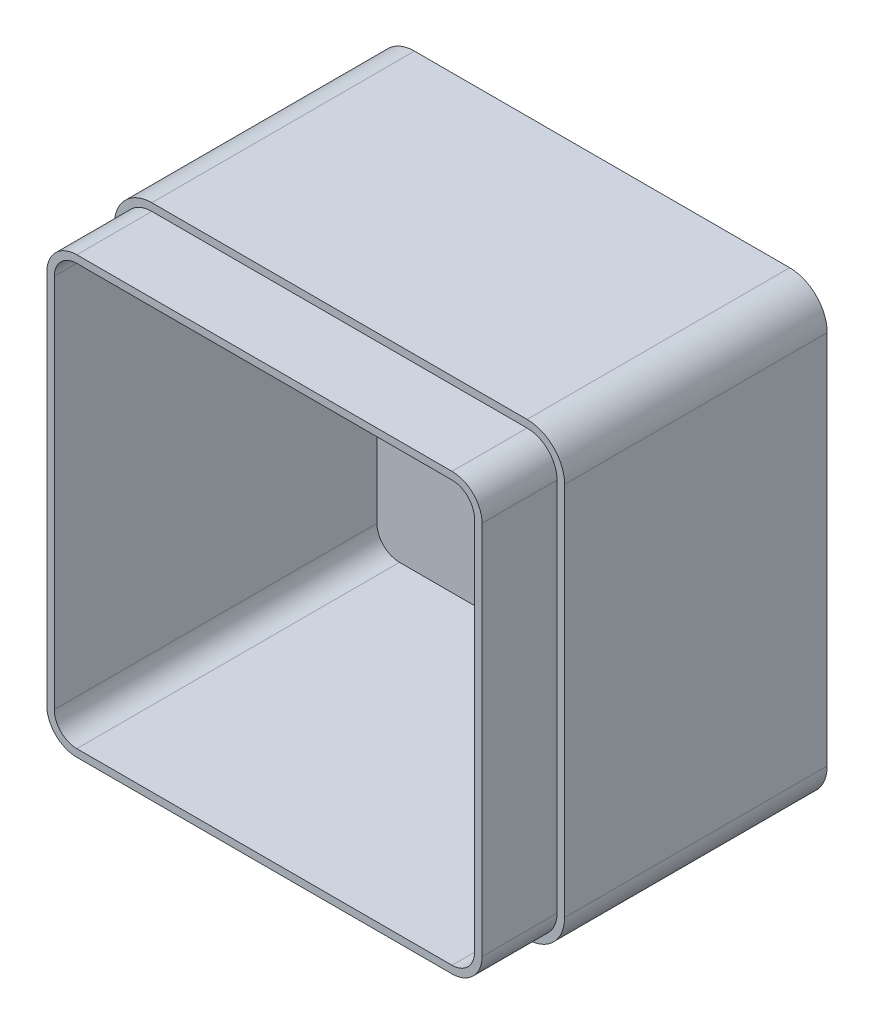
from build123d import *

# Parameters (mm, degrees)
SKETCH1_W           = 120
SKETCH1_H           = 120
BOSS_EXTRUDE1_DEPTH = 90
FILLET1_R           = 10
SHELL1_T            = -4
CUT_EXTRUDE1_DEPTH  = 20


with BuildPart() as part:
    # Sketch1 → Boss-Extrude1 (new body)
    with BuildSketch(Plane.XY):
        Rectangle(SKETCH1_W, SKETCH1_H)
    extrude(amount=BOSS_EXTRUDE1_DEPTH)

    # Fillet1
    fillet1_edges = [part.edges().sort_by_distance(p)[0] for p in [
        (-60, 60, 45),
        (60, 60, 45),
        (60, -60, 45),
        (-60, -60, 45),
    ]]
    fillet(fillet1_edges, radius=FILLET1_R)

    # Shell1
    shell1_openings = [part.faces().sort_by_distance(p)[0] for p in [
        (0, 0, 90),
    ]]
    offset(amount=SHELL1_T, openings=shell1_openings, kind=Kind.INTERSECTION)

    # Sketch2 → Cut-Extrude1 (cut)
    with BuildSketch(Plane.XY.offset(90)):
        with BuildLine():
            Line((-50, -60), (50, -60))
            ThreePointArc((50, -60), (57.071067812, -57.071067812), (60, -50))
            Line((60, -50), (60, 50))
            ThreePointArc((60, 50), (57.071067812, 57.071067812), (50, 60))
            Line((50, 60), (-50, 60))
            ThreePointArc((-50, 60), (-57.071067812, 57.071067812), (-60, 50))
            Line((-60, 50), (-60, -50))
            ThreePointArc((-60, -50), (-57.071067812, -57.071067812), (-50, -60))
        make_face()
        with BuildLine():
            Line((-50, -58), (50, -58))
            ThreePointArc((50, -58), (55.656854249, -55.656854249), (58, -50))
            Line((58, -50), (58, 50))
            ThreePointArc((58, 50), (55.656854249, 55.656854249), (50, 58))
            Line((50, 58), (-50, 58))
            ThreePointArc((-50, 58), (-55.656854249, 55.656854249), (-58, 50))
            Line((-58, 50), (-58, -50))
            ThreePointArc((-58, -50), (-55.656854249, -55.656854249), (-50, -58))
        make_face(mode=Mode.SUBTRACT)
    extrude(amount=-CUT_EXTRUDE1_DEPTH, mode=Mode.SUBTRACT)


solid = part.part
